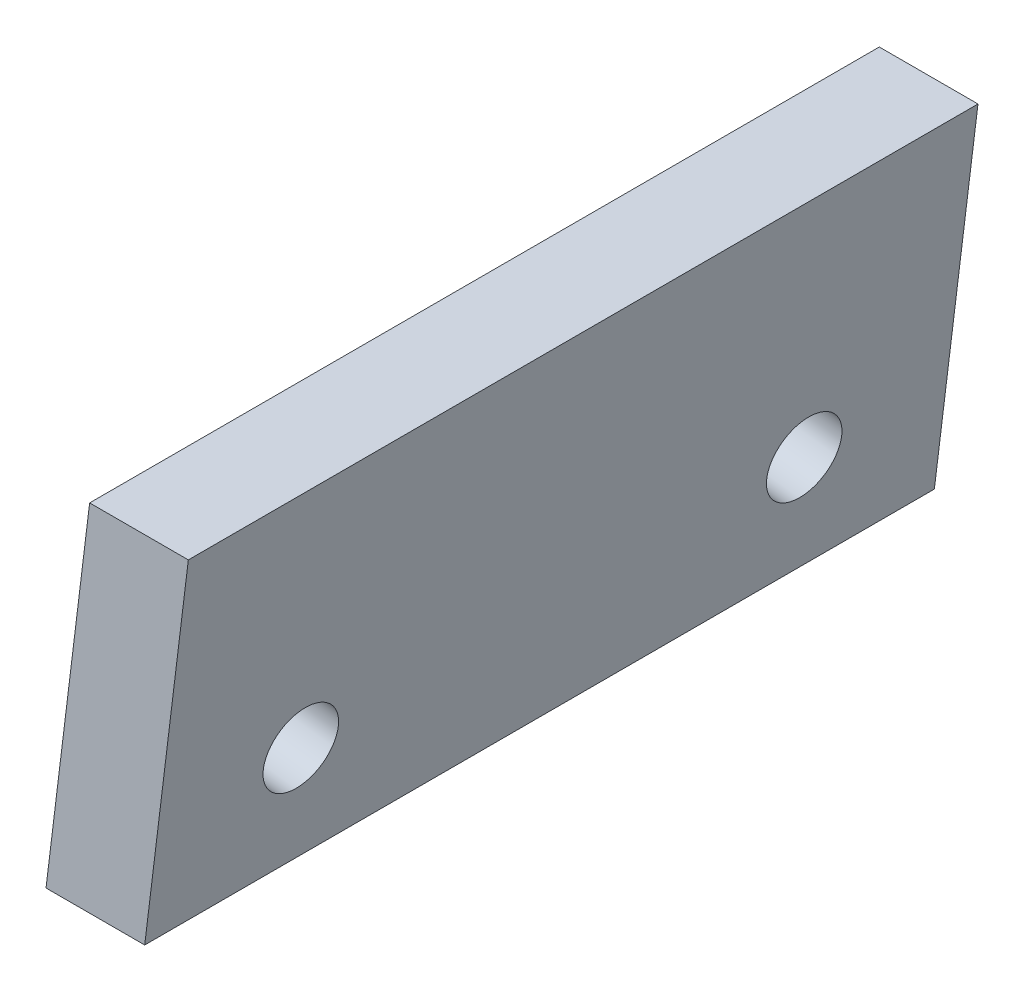
from build123d import *

# Parameters (mm, degrees)
BOSS_EXTRUDE2_DEPTH = 20
SKETCH4_R           = 0.95
CUT_EXTRUDE1_DEPTH  = 4.57818947


with BuildPart() as part:
    # Sketch2 → Boss-Extrude2 (new body)
    with BuildSketch(Plane.XY):
        Polygon((0, 0), (2.5, 0), (3.605061048, 9), (1.105061048, 9), align=None)
    extrude(amount=BOSS_EXTRUDE2_DEPTH)

    # Sketch4 → Cut-Extrude1 (cut, through all)
    with BuildSketch(Plane(origin=(0, 0, 0), x_dir=(0, 0, 1), z_dir=(-0.992546152, 0.121869343, 0))):
        with Locations((3.625, 3)):
            Circle(SKETCH4_R)
        with Locations((16.375, 3)):
            Circle(SKETCH4_R)
    extrude(amount=-CUT_EXTRUDE1_DEPTH, mode=Mode.SUBTRACT)


solid = part.part
